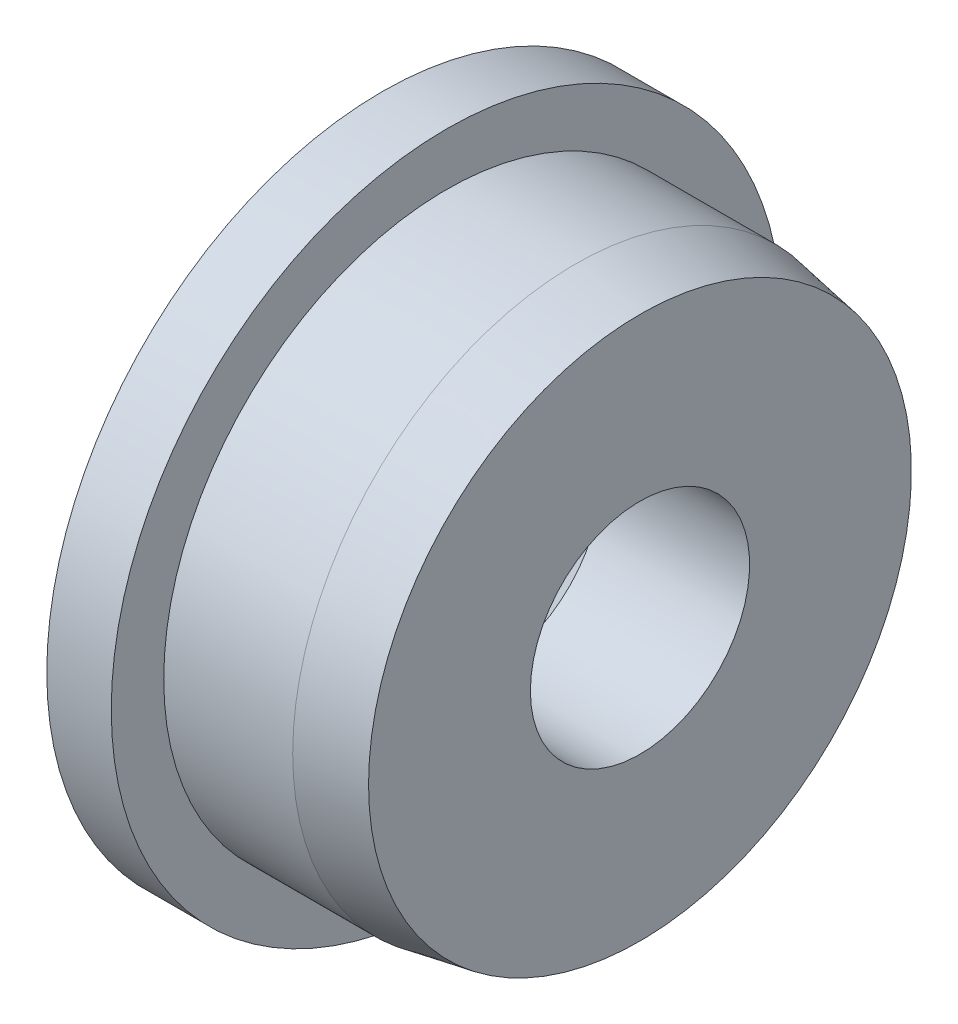
from build123d import *


with BuildPart() as part:
    # Sketch1 → Revolve1 (revolve)
    with BuildSketch(Plane.XY, mode=Mode.PRIVATE) as revolve1_sk:
        Polygon((3.81, 2.159), (0.889, 2.159), (-1.27, 4.318), (-1.27, 6.604), (0, 6.604), (0, 5.57022), (2.54, 5.57022), (3.81, 5.346284735), align=None)
    revolve(revolve1_sk.sketch.rotate(Axis((0, 0, 0), (1, 0, 0)), 90), axis=Axis((0, 0, 0), (1, 0, 0)))  # turned: the seam where the file's is


solid = part.part
